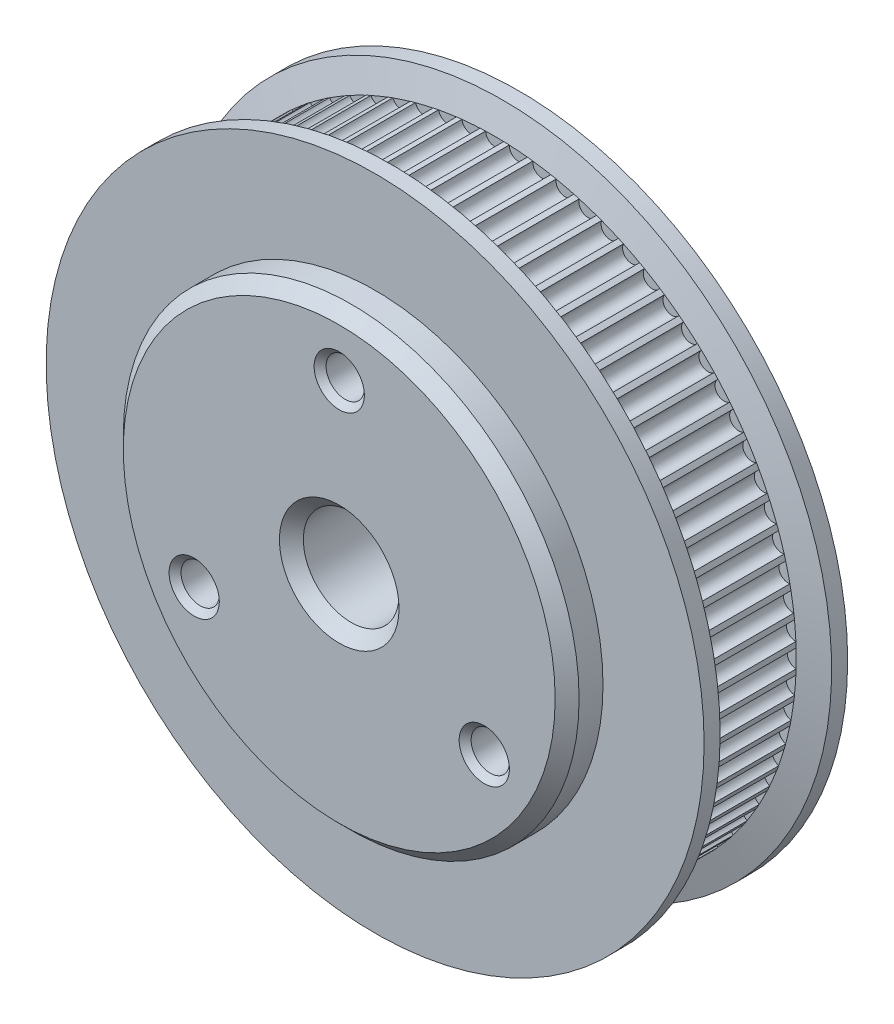
from build123d import *

# Parameters (mm, degrees)
BOSS_EXTRU_1_DEPTH           = 6
BOSS_EXTRU_1_DEPTH_BACK      = 6
ESQUISSE3_R                  = 27.5
BOSS_EXTRU_2_DEPTH           = 2
ESQUISSE7_R                  = 19.05
BOSS_EXTRU_3_DEPTH           = 3
ENL_V_MAT_EXTRU_1_DEPTH      = 40.918667312
ENL_V_MAT_EXTRU_1_DEPTH_BACK = 40.918667312
ESQUISSE6_R                  = 4
ESQUISSE6_R_2                = 1.6
CHANFREIN4_SIZE              = 1
CHANFREIN5_SIZE              = 0.5


with BuildPart() as part:
    # Esquisse1 → Boss.-Extru.1 (new, two sides: drawn at the far end of the back side and taken through both)
    with BuildSketch(Plane.XY.offset(-BOSS_EXTRU_1_DEPTH_BACK)):
        with BuildLine():
            ThreePointArc((0.759913653, -25.198044001), (0.989720325, -25.190064389), (1.219444654, -25.179988979))
            ThreePointArc((1.219444654, -25.179988979), (1.918285661, -24.374130351), (2.734586839, -25.060744703))
            ThreePointArc((2.734586839, -25.060744703), (2.963059021, -25.034759266), (3.191284678, -25.006690952))
            ThreePointArc((3.191284678, -25.006690952), (3.824744453, -24.148486083), (4.692400388, -24.76893758))
            ThreePointArc((4.692400388, -24.76893758), (4.918129473, -24.725106526), (5.143449372, -24.679218359))
            ThreePointArc((5.143449372, -24.679218359), (5.707622424, -23.773958369), (6.621283729, -24.32442172))
            ThreePointArc((6.621283729, -24.32442172), (6.842878021, -24.263015283), (7.06390299, -24.199590178))
            ThreePointArc((7.06390299, -24.199590178), (7.555311004, -23.252856295), (8.509344653, -23.729937712))
            ThreePointArc((8.509344653, -23.729937712), (8.72543795, -23.651334483), (8.940805297, -23.570763477))
            ThreePointArc((8.940805297, -23.570763477), (9.35641858, -22.58839263), (10.344942638, -22.989150747))
            ThreePointArc((10.344942638, -22.989150747), (10.554202653, -22.893835341), (10.762584566, -22.796615181))
            ThreePointArc((10.762584566, -22.796615181), (11.099840723, -21.784664013), (12.116760611, -22.106628023))
            ThreePointArc((12.116760611, -22.106628023), (12.317897188, -21.99518809), (12.518008922, -21.881918172))
            ThreePointArc((12.518008922, -21.881918172), (12.774828658, -20.846625698), (13.813874726, -21.087810586))
            ThreePointArc((13.813874726, -21.087810586), (14.005647789, -20.960933191), (14.196255591, -20.83231186))
            ThreePointArc((14.196255591, -20.83231186), (14.371055526, -19.780061004), (15.42582171, -19.938979784))
            ThreePointArc((15.42582171, -19.938979784), (15.607048915, -19.797447169), (15.786977623, -19.654267419))
            ThreePointArc((15.786977623, -19.654267419), (15.878680058, -18.591545656), (16.942663373, -18.667218541))
            ThreePointArc((16.942663373, -18.667218541), (17.112227395, -18.511903302), (17.280367689, -18.355047883))
            ThreePointArc((17.280367689, -18.355047883), (17.288407247, -17.288407247), (18.355047883, -17.280367689))
            ThreePointArc((18.355047883, -17.280367689), (18.511903302, -17.112227395), (18.667218541, -16.942663373))
            ThreePointArc((18.667218541, -16.942663373), (18.591545656, -15.878680058), (19.654267419, -15.786977623))
            ThreePointArc((19.654267419, -15.786977623), (19.797447169, -15.607048915), (19.938979784, -15.42582171))
            ThreePointArc((19.938979784, -15.42582171), (19.780061004, -14.371055526), (20.83231186, -14.196255591))
            ThreePointArc((20.83231186, -14.196255591), (20.960933191, -14.005647789), (21.087810586, -13.813874726))
            ThreePointArc((21.087810586, -13.813874726), (20.846625698, -12.774828658), (21.881918172, -12.518008922))
            ThreePointArc((21.881918172, -12.518008922), (21.99518809, -12.317897188), (22.106628023, -12.116760611))
            ThreePointArc((22.106628023, -12.116760611), (21.784664013, -11.099840723), (22.796615181, -10.762584566))
            ThreePointArc((22.796615181, -10.762584566), (22.893835341, -10.554202653), (22.989150747, -10.344942638))
            ThreePointArc((22.989150747, -10.344942638), (22.58839263, -9.35641858), (23.570763477, -8.940805297))
            ThreePointArc((23.570763477, -8.940805297), (23.651334483, -8.72543795), (23.729937712, -8.509344653))
            ThreePointArc((23.729937712, -8.509344653), (23.252856295, -7.555311004), (24.199590178, -7.06390299))
            ThreePointArc((24.199590178, -7.06390299), (24.263015283, -6.842878021), (24.32442172, -6.621283729))
            ThreePointArc((24.32442172, -6.621283729), (23.773958369, -5.707622424), (24.679218359, -5.143449372))
            ThreePointArc((24.679218359, -5.143449372), (24.725106526, -4.918129473), (24.76893758, -4.692400388))
            ThreePointArc((24.76893758, -4.692400388), (24.148486083, -3.824744453), (25.006690952, -3.191284678))
            ThreePointArc((25.006690952, -3.191284678), (25.034759266, -2.963059021), (25.060744703, -2.734586839))
            ThreePointArc((25.060744703, -2.734586839), (24.374130351, -1.918285661), (25.179988979, -1.219444654))
            ThreePointArc((25.179988979, -1.219444654), (25.190064389, -0.989720325), (25.198044001, -0.759913653))
            ThreePointArc((25.198044001, -0.759913653), (24.4495, 0), (25.198044001, 0.759913653))
            ThreePointArc((25.198044001, 0.759913653), (25.190064389, 0.989720325), (25.179988979, 1.219444654))
            ThreePointArc((25.179988979, 1.219444654), (24.374130351, 1.918285661), (25.060744703, 2.734586839))
            ThreePointArc((25.060744703, 2.734586839), (25.034759266, 2.963059021), (25.006690952, 3.191284678))
            ThreePointArc((25.006690952, 3.191284678), (24.148486083, 3.824744453), (24.76893758, 4.692400388))
            ThreePointArc((24.76893758, 4.692400388), (24.725106526, 4.918129473), (24.679218359, 5.143449372))
            ThreePointArc((24.679218359, 5.143449372), (23.773958369, 5.707622424), (24.32442172, 6.621283729))
            ThreePointArc((24.32442172, 6.621283729), (24.263015283, 6.842878021), (24.199590178, 7.06390299))
            ThreePointArc((24.199590178, 7.06390299), (23.252856295, 7.555311004), (23.729937712, 8.509344653))
            ThreePointArc((23.729937712, 8.509344653), (23.651334483, 8.72543795), (23.570763477, 8.940805297))
            ThreePointArc((23.570763477, 8.940805297), (22.58839263, 9.35641858), (22.989150747, 10.344942638))
            ThreePointArc((22.989150747, 10.344942638), (22.893835341, 10.554202653), (22.796615181, 10.762584566))
            ThreePointArc((22.796615181, 10.762584566), (21.784664013, 11.099840723), (22.106628023, 12.116760611))
            ThreePointArc((22.106628023, 12.116760611), (21.99518809, 12.317897188), (21.881918172, 12.518008922))
            ThreePointArc((21.881918172, 12.518008922), (20.846625698, 12.774828658), (21.087810586, 13.813874726))
            ThreePointArc((21.087810586, 13.813874726), (20.960933191, 14.005647789), (20.83231186, 14.196255591))
            ThreePointArc((20.83231186, 14.196255591), (19.780061004, 14.371055526), (19.938979784, 15.42582171))
            ThreePointArc((19.938979784, 15.42582171), (19.797447169, 15.607048915), (19.654267419, 15.786977623))
            ThreePointArc((19.654267419, 15.786977623), (18.591545656, 15.878680058), (18.667218541, 16.942663373))
            ThreePointArc((18.667218541, 16.942663373), (18.511903302, 17.112227395), (18.355047883, 17.280367689))
            ThreePointArc((18.355047883, 17.280367689), (17.288407247, 17.288407247), (17.280367689, 18.355047883))
            ThreePointArc((17.280367689, 18.355047883), (17.112227395, 18.511903302), (16.942663373, 18.667218541))
            ThreePointArc((16.942663373, 18.667218541), (15.878680058, 18.591545656), (15.786977623, 19.654267419))
            ThreePointArc((15.786977623, 19.654267419), (15.607048915, 19.797447169), (15.42582171, 19.938979784))
            ThreePointArc((15.42582171, 19.938979784), (14.371055526, 19.780061004), (14.196255591, 20.83231186))
            ThreePointArc((14.196255591, 20.83231186), (14.005647789, 20.960933191), (13.813874726, 21.087810586))
            ThreePointArc((13.813874726, 21.087810586), (12.774828658, 20.846625698), (12.518008922, 21.881918172))
            ThreePointArc((12.518008922, 21.881918172), (12.317897188, 21.99518809), (12.116760611, 22.106628023))
            ThreePointArc((12.116760611, 22.106628023), (11.099840723, 21.784664013), (10.762584566, 22.796615181))
            ThreePointArc((10.762584566, 22.796615181), (10.554202653, 22.893835341), (10.344942638, 22.989150747))
            ThreePointArc((10.344942638, 22.989150747), (9.35641858, 22.58839263), (8.940805297, 23.570763477))
            ThreePointArc((8.940805297, 23.570763477), (8.72543795, 23.651334483), (8.509344653, 23.729937712))
            ThreePointArc((8.509344653, 23.729937712), (7.555311004, 23.252856295), (7.06390299, 24.199590178))
            ThreePointArc((7.06390299, 24.199590178), (6.842878021, 24.263015283), (6.621283729, 24.32442172))
            ThreePointArc((6.621283729, 24.32442172), (5.707622424, 23.773958369), (5.143449372, 24.679218359))
            ThreePointArc((5.143449372, 24.679218359), (4.918129473, 24.725106526), (4.692400388, 24.76893758))
            ThreePointArc((4.692400388, 24.76893758), (3.824744453, 24.148486083), (3.191284678, 25.006690952))
            ThreePointArc((3.191284678, 25.006690952), (2.963059021, 25.034759266), (2.734586839, 25.060744703))
            ThreePointArc((2.734586839, 25.060744703), (1.918285661, 24.374130351), (1.219444654, 25.179988979))
            ThreePointArc((1.219444654, 25.179988979), (0.989720325, 25.190064389), (0.759913653, 25.198044001))
            ThreePointArc((0.759913653, 25.198044001), (0, 24.4495), (-0.759913653, 25.198044001))
            ThreePointArc((-0.759913653, 25.198044001), (-0.989720325, 25.190064389), (-1.219444654, 25.179988979))
            ThreePointArc((-1.219444654, 25.179988979), (-1.918285661, 24.374130351), (-2.734586839, 25.060744703))
            ThreePointArc((-2.734586839, 25.060744703), (-2.963059021, 25.034759266), (-3.191284678, 25.006690952))
            ThreePointArc((-3.191284678, 25.006690952), (-3.824744453, 24.148486083), (-4.692400388, 24.76893758))
            ThreePointArc((-4.692400388, 24.76893758), (-4.918129473, 24.725106526), (-5.143449372, 24.679218359))
            ThreePointArc((-5.143449372, 24.679218359), (-5.707622424, 23.773958369), (-6.621283729, 24.32442172))
            ThreePointArc((-6.621283729, 24.32442172), (-6.842878021, 24.263015283), (-7.06390299, 24.199590178))
            ThreePointArc((-7.06390299, 24.199590178), (-7.555311004, 23.252856295), (-8.509344653, 23.729937712))
            ThreePointArc((-8.509344653, 23.729937712), (-8.72543795, 23.651334483), (-8.940805297, 23.570763477))
            ThreePointArc((-8.940805297, 23.570763477), (-9.35641858, 22.58839263), (-10.344942638, 22.989150747))
            ThreePointArc((-10.344942638, 22.989150747), (-10.554202653, 22.893835341), (-10.762584566, 22.796615181))
            ThreePointArc((-10.762584566, 22.796615181), (-11.099840723, 21.784664013), (-12.116760611, 22.106628023))
            ThreePointArc((-12.116760611, 22.106628023), (-12.317897188, 21.99518809), (-12.518008922, 21.881918172))
            ThreePointArc((-12.518008922, 21.881918172), (-12.774828658, 20.846625698), (-13.813874726, 21.087810586))
            ThreePointArc((-13.813874726, 21.087810586), (-14.005647789, 20.960933191), (-14.196255591, 20.83231186))
            ThreePointArc((-14.196255591, 20.83231186), (-14.371055526, 19.780061004), (-15.42582171, 19.938979784))
            ThreePointArc((-15.42582171, 19.938979784), (-15.607048915, 19.797447169), (-15.786977623, 19.654267419))
            ThreePointArc((-15.786977623, 19.654267419), (-15.878680058, 18.591545656), (-16.942663373, 18.667218541))
            ThreePointArc((-16.942663373, 18.667218541), (-17.112227395, 18.511903302), (-17.280367689, 18.355047883))
            ThreePointArc((-17.280367689, 18.355047883), (-17.288407247, 17.288407247), (-18.355047883, 17.280367689))
            ThreePointArc((-18.355047883, 17.280367689), (-18.511903302, 17.112227395), (-18.667218541, 16.942663373))
            ThreePointArc((-18.667218541, 16.942663373), (-18.591545656, 15.878680058), (-19.654267419, 15.786977623))
            ThreePointArc((-19.654267419, 15.786977623), (-19.797447169, 15.607048915), (-19.938979784, 15.42582171))
            ThreePointArc((-19.938979784, 15.42582171), (-19.780061004, 14.371055526), (-20.83231186, 14.196255591))
            ThreePointArc((-20.83231186, 14.196255591), (-20.960933191, 14.005647789), (-21.087810586, 13.813874726))
            ThreePointArc((-21.087810586, 13.813874726), (-20.846625698, 12.774828658), (-21.881918172, 12.518008922))
            ThreePointArc((-21.881918172, 12.518008922), (-21.99518809, 12.317897188), (-22.106628023, 12.116760611))
            ThreePointArc((-22.106628023, 12.116760611), (-21.784664013, 11.099840723), (-22.796615181, 10.762584566))
            ThreePointArc((-22.796615181, 10.762584566), (-22.893835341, 10.554202653), (-22.989150747, 10.344942638))
            ThreePointArc((-22.989150747, 10.344942638), (-22.58839263, 9.35641858), (-23.570763477, 8.940805297))
            ThreePointArc((-23.570763477, 8.940805297), (-23.651334483, 8.72543795), (-23.729937712, 8.509344653))
            ThreePointArc((-23.729937712, 8.509344653), (-23.252856295, 7.555311004), (-24.199590178, 7.06390299))
            ThreePointArc((-24.199590178, 7.06390299), (-24.263015283, 6.842878021), (-24.32442172, 6.621283729))
            ThreePointArc((-24.32442172, 6.621283729), (-23.773958369, 5.707622424), (-24.679218359, 5.143449372))
            ThreePointArc((-24.679218359, 5.143449372), (-24.725106526, 4.918129473), (-24.76893758, 4.692400388))
            ThreePointArc((-24.76893758, 4.692400388), (-24.148486083, 3.824744453), (-25.006690952, 3.191284678))
            ThreePointArc((-25.006690952, 3.191284678), (-25.034759266, 2.963059021), (-25.060744703, 2.734586839))
            ThreePointArc((-25.060744703, 2.734586839), (-24.374130351, 1.918285661), (-25.179988979, 1.219444654))
            ThreePointArc((-25.179988979, 1.219444654), (-25.190064389, 0.989720325), (-25.198044001, 0.759913653))
            ThreePointArc((-25.198044001, 0.759913653), (-24.4495, 0), (-25.198044001, -0.759913653))
            ThreePointArc((-25.198044001, -0.759913653), (-25.190064389, -0.989720325), (-25.179988979, -1.219444654))
            ThreePointArc((-25.179988979, -1.219444654), (-24.374130351, -1.918285661), (-25.060744703, -2.734586839))
            ThreePointArc((-25.060744703, -2.734586839), (-25.034759266, -2.963059021), (-25.006690952, -3.191284678))
            ThreePointArc((-25.006690952, -3.191284678), (-24.148486083, -3.824744453), (-24.76893758, -4.692400388))
            ThreePointArc((-24.76893758, -4.692400388), (-24.725106526, -4.918129473), (-24.679218359, -5.143449372))
            ThreePointArc((-24.679218359, -5.143449372), (-23.773958369, -5.707622424), (-24.32442172, -6.621283729))
            ThreePointArc((-24.32442172, -6.621283729), (-24.263015283, -6.842878021), (-24.199590178, -7.06390299))
            ThreePointArc((-24.199590178, -7.06390299), (-23.252856295, -7.555311004), (-23.729937712, -8.509344653))
            ThreePointArc((-23.729937712, -8.509344653), (-23.651334483, -8.72543795), (-23.570763477, -8.940805297))
            ThreePointArc((-23.570763477, -8.940805297), (-22.58839263, -9.35641858), (-22.989150747, -10.344942638))
            ThreePointArc((-22.989150747, -10.344942638), (-22.893835341, -10.554202653), (-22.796615181, -10.762584566))
            ThreePointArc((-22.796615181, -10.762584566), (-21.784664013, -11.099840723), (-22.106628023, -12.116760611))
            ThreePointArc((-22.106628023, -12.116760611), (-21.99518809, -12.317897188), (-21.881918172, -12.518008922))
            ThreePointArc((-21.881918172, -12.518008922), (-20.846625698, -12.774828658), (-21.087810586, -13.813874726))
            ThreePointArc((-21.087810586, -13.813874726), (-20.960933191, -14.005647789), (-20.83231186, -14.196255591))
            ThreePointArc((-20.83231186, -14.196255591), (-19.780061004, -14.371055526), (-19.938979784, -15.42582171))
            ThreePointArc((-19.938979784, -15.42582171), (-19.797447169, -15.607048915), (-19.654267419, -15.786977623))
            ThreePointArc((-19.654267419, -15.786977623), (-18.591545656, -15.878680058), (-18.667218541, -16.942663373))
            ThreePointArc((-18.667218541, -16.942663373), (-18.511903302, -17.112227395), (-18.355047883, -17.280367689))
            ThreePointArc((-18.355047883, -17.280367689), (-17.288407247, -17.288407247), (-17.280367689, -18.355047883))
            ThreePointArc((-17.280367689, -18.355047883), (-17.112227395, -18.511903302), (-16.942663373, -18.667218541))
            ThreePointArc((-16.942663373, -18.667218541), (-15.878680058, -18.591545656), (-15.786977623, -19.654267419))
            ThreePointArc((-15.786977623, -19.654267419), (-15.607048915, -19.797447169), (-15.42582171, -19.938979784))
            ThreePointArc((-15.42582171, -19.938979784), (-14.371055526, -19.780061004), (-14.196255591, -20.83231186))
            ThreePointArc((-14.196255591, -20.83231186), (-14.005647789, -20.960933191), (-13.813874726, -21.087810586))
            ThreePointArc((-13.813874726, -21.087810586), (-12.774828658, -20.846625698), (-12.518008922, -21.881918172))
            ThreePointArc((-12.518008922, -21.881918172), (-12.317897188, -21.99518809), (-12.116760611, -22.106628023))
            ThreePointArc((-12.116760611, -22.106628023), (-11.099840723, -21.784664013), (-10.762584566, -22.796615181))
            ThreePointArc((-10.762584566, -22.796615181), (-10.554202653, -22.893835341), (-10.344942638, -22.989150747))
            ThreePointArc((-10.344942638, -22.989150747), (-9.35641858, -22.58839263), (-8.940805297, -23.570763477))
            ThreePointArc((-8.940805297, -23.570763477), (-8.72543795, -23.651334483), (-8.509344653, -23.729937712))
            ThreePointArc((-8.509344653, -23.729937712), (-7.555311004, -23.252856295), (-7.06390299, -24.199590178))
            ThreePointArc((-7.06390299, -24.199590178), (-6.842878021, -24.263015283), (-6.621283729, -24.32442172))
            ThreePointArc((-6.621283729, -24.32442172), (-5.707622424, -23.773958369), (-5.143449372, -24.679218359))
            ThreePointArc((-5.143449372, -24.679218359), (-4.918129473, -24.725106526), (-4.692400388, -24.76893758))
            ThreePointArc((-4.692400388, -24.76893758), (-3.824744453, -24.148486083), (-3.191284678, -25.006690952))
            ThreePointArc((-3.191284678, -25.006690952), (-2.963059021, -25.034759266), (-2.734586839, -25.060744703))
            ThreePointArc((-2.734586839, -25.060744703), (-1.918285661, -24.374130351), (-1.219444654, -25.179988979))
            ThreePointArc((-1.219444654, -25.179988979), (-0.989720325, -25.190064389), (-0.759913653, -25.198044001))
            ThreePointArc((-0.759913653, -25.198044001), (0, -24.4495), (0.759913653, -25.198044001))
        make_face()
    extrude(amount=BOSS_EXTRU_1_DEPTH + BOSS_EXTRU_1_DEPTH_BACK)

    # Esquisse3 → Boss.-Extru.2 (add)
    with BuildSketch(Plane.XY.offset(6)):
        Circle(ESQUISSE3_R)
    boss_extru_2 = extrude(amount=-BOSS_EXTRU_2_DEPTH)

    # Esquisse4 → Enlèvement de matière-Révolution1 (revolve, cut)
    with BuildSketch(Plane(origin=(0, 0, 0), x_dir=(0, 0, -1), z_dir=(1, 0, 0))):
        Polygon((-4, 25.198044001), (-5.35108909, 29.909851608), (-1.448526425, 29.909851608), align=None)
    enl_vement_de_mati_re_r_volution1 = revolve(axis=Axis((0, 0, 9.447235621), (0, 0, -1)), mode=Mode.SUBTRACT)

    # Symétrie1: Boss.-Extru.2, Enlèvement de matière-Révolution1 across plane
    add(boss_extru_2.mirror(Plane.XY))
    add(enl_vement_de_mati_re_r_volution1.mirror(Plane.XY), mode=Mode.SUBTRACT)

    # Esquisse7 → Boss.-Extru.3 (add)
    with BuildSketch(Plane.XY.offset(6)):
        Circle(ESQUISSE7_R)
    extrude(amount=BOSS_EXTRU_3_DEPTH)

    # Esquisse6 → Enlèv. mat.-Extru.1 (cut, two sides: drawn at the far end of the back side and taken through both)
    with BuildSketch(Plane.XY.offset(-ENL_V_MAT_EXTRU_1_DEPTH_BACK)):
        Circle(ESQUISSE6_R)
        with Locations((0, 14)):
            Circle(ESQUISSE6_R_2)
        with Locations((12.124355653, -7)):
            Circle(ESQUISSE6_R_2)
        with Locations((-12.124355653, -7)):
            Circle(ESQUISSE6_R_2)
    extrude(amount=ENL_V_MAT_EXTRU_1_DEPTH + ENL_V_MAT_EXTRU_1_DEPTH_BACK, mode=Mode.SUBTRACT)

    # Chanfrein4
    chanfrein4_edges = [part.edges().sort_by_distance(p)[0] for p in [
        (-4, 0, 9),
        (-4, 0, -6),
        (-19.05, 0, 9),
    ]]
    chamfer(chanfrein4_edges, length=CHANFREIN4_SIZE)

    # Chanfrein5
    chanfrein5_edges = [part.edges().sort_by_distance(p)[0] for p in [
        (-13.724355653, -7, -6),
        (10.524355653, -7, -6),
        (-1.6, 14, -6),
        (-13.724355653, -7, 9),
        (-1.6, 14, 9),
        (10.524355653, -7, 9),
    ]]
    chamfer(chanfrein5_edges, length=CHANFREIN5_SIZE)


solid = part.part
